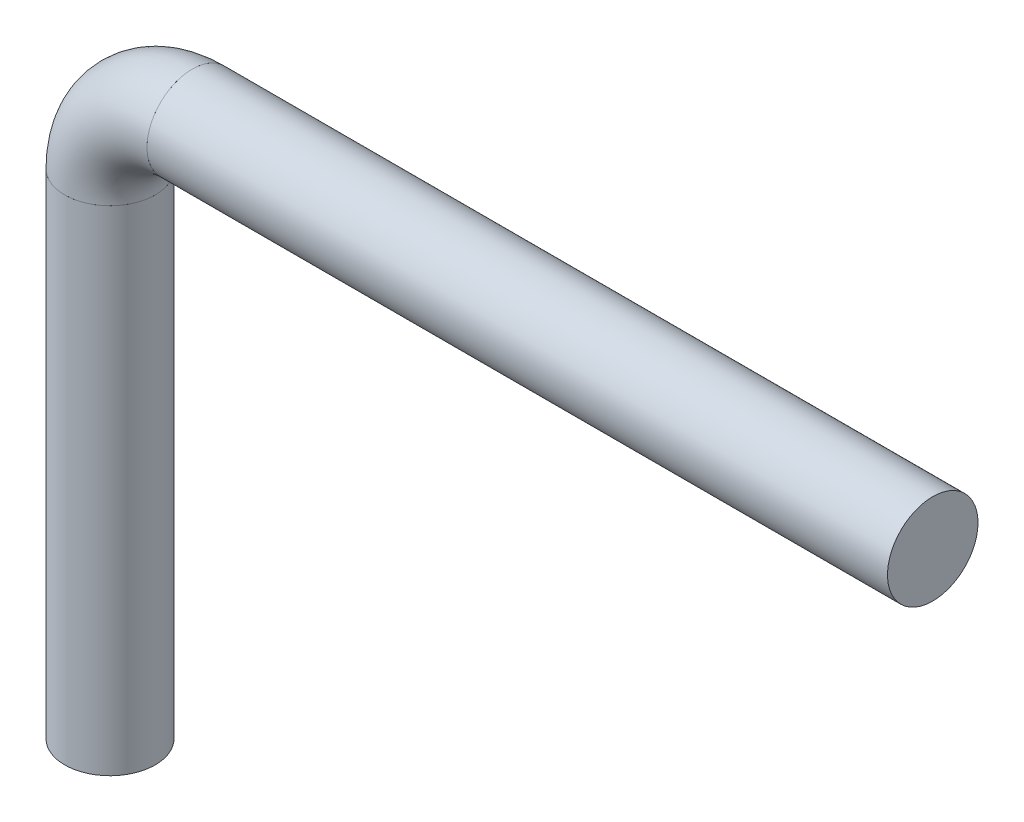
from build123d import *

# Parameters (mm, degrees)
SKETCH6_R           = 0.55
BOSS_EXTRUDE1_DEPTH = 6
SKETCH11_R          = 0.55
BOSS_EXTRUDE2_DEPTH = 9
SKETCH22_R          = 0.55
REVOLVE1_ANGLE      = 90


with BuildPart() as part:
    # Sketch6 → Boss-Extrude1 (new body)
    with BuildSketch(Plane(origin=(0, 6, 0), x_dir=(-1, 0, 0), z_dir=(0, -1, 0))):
        Circle(SKETCH6_R)
    extrude(amount=BOSS_EXTRUDE1_DEPTH)


with BuildPart() as body_2:
    # Sketch11 → Boss-Extrude2 (new body)
    with BuildSketch(Plane(origin=(1, 0, 0), x_dir=(0, 0, -1), z_dir=(1, 0, 0))):
        with Locations((0, 7)):
            Circle(SKETCH11_R)
    extrude(amount=BOSS_EXTRUDE2_DEPTH)


with BuildPart() as body_3:
    # Sketch22 → Revolve1 (revolve)
    with BuildSketch(Plane.ZY.offset(-1)):
        with Locations((0, 7)):
            Circle(SKETCH22_R)
    revolve(axis=Axis((1, 6, -0.280897507), (0, 0, 1)), revolution_arc=REVOLVE1_ANGLE)


solid = Compound([part.part, body_2.part, body_3.part])
